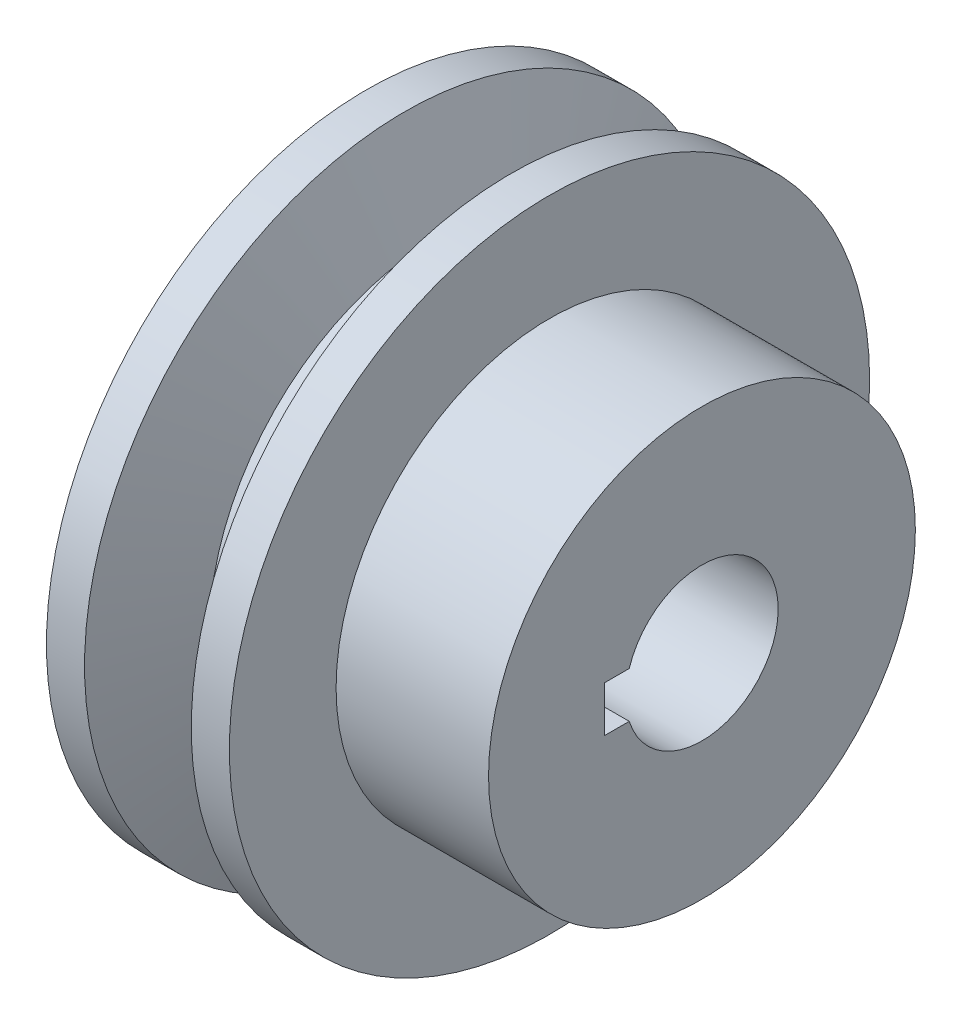
from build123d import *

# Parameters (mm, degrees)
CUT_EXTRUDE1_DEPTH = 23


with BuildPart() as part:
    # Sketch1 → Revolve1 (revolve)
    with BuildSketch(Plane.XY):
        Polygon((22, 0), (0, 0), (0, 21), (2.5, 21), (4.683821406, 15), (7.316178594, 15), (9.5, 21), (12, 21), (12, 14), (22, 14), align=None)
    revolve(axis=Axis((22, 0, 0), (-1, 0, 0)))

    # Sketch2 → Cut-Extrude1 (cut, through all)
    with BuildSketch(Plane.ZY):
        with BuildLine():
            Line((6.4, 1.5), (6.4, -1.5))
            Line((6.4, -1.5), (4.769696007, -1.5))
            ThreePointArc((4.769696007, -1.5), (-5, 0), (4.769696007, 1.5))
            Line((4.769696007, 1.5), (6.4, 1.5))
        make_face()
    extrude(amount=-CUT_EXTRUDE1_DEPTH, mode=Mode.SUBTRACT)


solid = part.part
